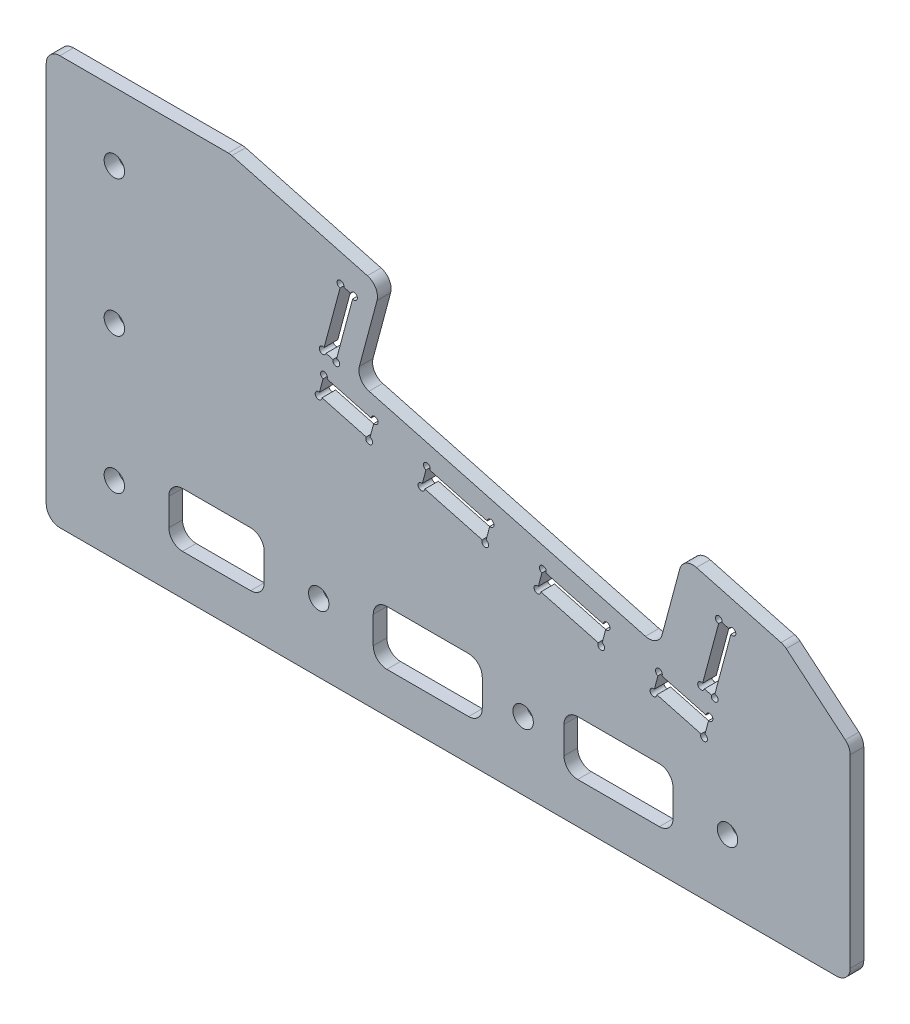
from build123d import *

# Parameters (mm, degrees)
SKETCH_1_W           = 130
SKETCH_1_H           = 60
SKETCH_1_R           = 1.5
EXTRUDE_1_DEPTH      = 2
CUT_EXTRUDE_1_DEPTH  = 3
CUT_EXTRUDE_2_DEPTH  = 3
CUT_EXTRUDE_5_DEPTH  = 10
CUT_EXTRUDE_6_DEPTH  = 3
FILLET_1_R           = 2
CUT_EXTRUDE_7_DEPTH  = 3
CUT_EXTRUDE_8_DEPTH  = 10
CUT_EXTRUDE_9_DEPTH  = 10
EXTRUDE_2_DEPTH      = 2
SKETCH_9_R           = 0.5
CUT_EXTRUDE_10_DEPTH = 10


with BuildPart() as part:
    # 草图1 → 凸台-拉伸1 (new body)
    with BuildSketch(Plane.XY):
        with Locations((65, 30)):
            Rectangle(SKETCH_1_W, SKETCH_1_H)
        with Locations((10, 10)):
            Circle(SKETCH_1_R, mode=Mode.SUBTRACT)
        with Locations((10, 30)):
            Circle(SKETCH_1_R, mode=Mode.SUBTRACT)
        with Locations((10, 50)):
            Circle(SKETCH_1_R, mode=Mode.SUBTRACT)
        with Locations((40, 10)):
            Circle(SKETCH_1_R, mode=Mode.SUBTRACT)
        with Locations((70, 10)):
            Circle(SKETCH_1_R, mode=Mode.SUBTRACT)
        with Locations((100, 10)):
            Circle(SKETCH_1_R, mode=Mode.SUBTRACT)
    extrude(amount=EXTRUDE_1_DEPTH)

    # 草图2 → 切除-拉伸1 (cut, through all)
    with BuildSketch(Plane.XY.offset(2)):
        Polygon((27, 60), (130, 32.40123318), (130, 60), align=None)
    extrude(amount=-CUT_EXTRUDE_1_DEPTH, mode=Mode.SUBTRACT)

    # 草图3 → 切除-拉伸2 (cut, through all)
    with BuildSketch(Plane.XY.offset(2)):
        Polygon((49.071405131, 54.085984819), (93.50399314, 42.180308745), (89.880526509, 28.657347177), (45.447938499, 40.563023251), align=None)
    extrude(amount=-CUT_EXTRUDE_2_DEPTH, mode=Mode.SUBTRACT)

    # 草图4 → 切除-拉伸5 (cut)
    with BuildSketch(Plane.XY.offset(2)):
        Polygon((98.74723483, 36.634281646), (96.159044379, 26.975023383), (98.090896032, 26.457385293), (100.679086483, 36.116643556), align=None)
        Polygon((45.138351471, 50.99873865), (42.55016102, 41.339480387), (40.618309368, 41.857118477), (43.206499819, 51.51637674), align=None)
    extrude(amount=-CUT_EXTRUDE_5_DEPTH, mode=Mode.SUBTRACT)

    # 草图5 → 切除-拉伸6 (cut, through all)
    with BuildSketch(Plane.XY.offset(2)):
        Polygon((130, 20), (130, 32.40123318), (108.287273653, 38.21914067), (118, 30.069195574), (118, 0), (130, 0), align=None)
    extrude(amount=-CUT_EXTRUDE_6_DEPTH, mode=Mode.SUBTRACT)

    # 圆角1
    fillet_1_edges = [part.edges().sort_by_distance(p)[0] for p in [
        (118, 30.069195574, 1),
        (108.287273653, 38.21914067, 1),
        (118, 0, 1),
        (27, 60, 1),
        (45.447938499, 40.563023251, 1),
        (49.071405131, 54.085984819, 1),
        (93.50399314, 42.180308745, 1),
        (89.880526509, 28.657347177, 1),
        (0, 60, 1),
        (0, 0, 1),
    ]]
    fillet(fillet_1_edges, radius=FILLET_1_R)

    # 草图6 → 切除-拉伸7 (cut)
    with BuildSketch(Plane(origin=(0, 0, 0), x_dir=(-1, 0, 0), z_dir=(0, 0, -1))):
        with BuildLine():
            Line((-78, 14), (-90, 14))
            ThreePointArc((-90, 14), (-91.414213562, 13.414213562), (-92, 12))
            Line((-92, 12), (-92, 8))
            ThreePointArc((-92, 8), (-91.414213562, 6.585786438), (-90, 6))
            Line((-90, 6), (-78, 6))
            ThreePointArc((-78, 6), (-76.585786438, 6.585786438), (-76, 8))
            Line((-76, 8), (-76, 12))
            ThreePointArc((-76, 12), (-76.585786438, 13.414213562), (-78, 14))
        make_face()
        with BuildLine():
            Line((-50, 14), (-62, 14))
            ThreePointArc((-62, 14), (-63.414213562, 13.414213562), (-64, 12))
            Line((-64, 12), (-64, 8))
            ThreePointArc((-64, 8), (-63.414213562, 6.585786438), (-62, 6))
            Line((-62, 6), (-50, 6))
            ThreePointArc((-50, 6), (-48.585786438, 6.585786438), (-48, 8))
            Line((-48, 8), (-48, 12))
            ThreePointArc((-48, 12), (-48.585786438, 13.414213562), (-50, 14))
        make_face()
        with BuildLine():
            Line((-20, 14), (-30, 14))
            ThreePointArc((-30, 14), (-31.414213562, 13.414213562), (-32, 12))
            Line((-32, 12), (-32, 8))
            ThreePointArc((-32, 8), (-31.414213562, 6.585786438), (-30, 6))
            Line((-30, 6), (-20, 6))
            ThreePointArc((-20, 6), (-18.585786438, 6.585786438), (-18, 8))
            Line((-18, 8), (-18, 12))
            ThreePointArc((-18, 12), (-18.585786438, 13.414213562), (-20, 14))
        make_face()
    extrude(amount=-CUT_EXTRUDE_7_DEPTH, mode=Mode.SUBTRACT)

    # 草图7 → 切除-拉伸8 (cut)
    with BuildSketch(Plane.XY.offset(2)):
        Polygon((97.314438897, 23.559607814), (89.944424842, 25.534397129), (89.167967707, 22.63661965), (96.537981761, 20.661830336), align=None)
        Polygon((81.440561097, 24.70717201), (82.217018232, 27.604949489), (72.915152525, 30.097376894), (72.138695389, 27.199599415), align=None)
        Polygon((64.411288779, 29.270151776), (65.187745914, 32.167929255), (55.885880207, 34.660356659), (55.109423072, 31.76257918), align=None)
        Polygon((47.382016462, 33.833131541), (48.158473597, 36.73090902), (40.788459542, 38.705698334), (40.012002407, 35.807920855), align=None)
    extrude(amount=-CUT_EXTRUDE_8_DEPTH, mode=Mode.SUBTRACT)

    # 草图8 → 切除-拉伸9 (cut)
    with BuildSketch(Plane.XY.offset(2)):
        Polygon((98.726021627, 36.671023993), (96.122302033, 26.95381018), (98.112109235, 26.420642947), (100.715828829, 36.13785676), align=None)
        Polygon((97.351181243, 23.580821018), (89.923211639, 25.571139475), (89.131225361, 22.615406446), (96.559194965, 20.625087989), align=None)
        Polygon((81.4617743, 24.670429664), (82.253760578, 27.626162693), (72.893939321, 30.13411924), (72.101953043, 27.178386211), align=None)
        Polygon((64.432501982, 29.23340943), (65.22448826, 32.189142458), (55.864667004, 34.697099005), (55.072680726, 31.741365977), align=None)
        Polygon((47.403229665, 33.796389195), (48.195215943, 36.752122223), (40.767246339, 38.74244068), (39.975260061, 35.786707652), align=None)
        Polygon((43.185286615, 51.553119086), (40.581567022, 41.835905273), (42.571374224, 41.302738041), (45.175093818, 51.019951853), align=None)
    extrude(amount=-CUT_EXTRUDE_9_DEPTH, mode=Mode.SUBTRACT)

    # 草图10 → 凸台-拉伸2 (add)
    with BuildSketch(Plane.XY.offset(2)):
        Polygon((40.767246339, 38.74244068), (48.195215943, 36.752122223), (48.169334038, 36.65552964), (40.741364434, 38.645848097), align=None)
        Polygon((39.975260061, 35.786707652), (47.403229665, 33.796389195), (47.42911157, 33.892981777), (40.001141965, 35.883300234), align=None)
        Polygon((55.864667004, 34.697099005), (55.838785099, 34.600506422), (65.196979694, 32.092985738), (65.222861598, 32.189578321), align=None)
        Polygon((64.432501982, 29.23340943), (55.072680726, 31.741365977), (55.09856263, 31.837958559), (64.458383887, 29.330002012), align=None)
        Polygon((72.893939321, 30.13411924), (82.253760578, 27.626162693), (82.227878673, 27.52957011), (72.868057417, 30.037526657), align=None)
        Polygon((81.4617743, 24.670429664), (72.101953043, 27.178386211), (72.127834948, 27.274978794), (81.487656204, 24.767022247), align=None)
        Polygon((89.923211639, 25.571139475), (97.351181243, 23.580821018), (97.325299338, 23.484228435), (89.897329734, 25.474546892), align=None)
        Polygon((96.559194965, 20.625087989), (89.131225361, 22.615406446), (89.157107265, 22.711999029), (96.585076869, 20.721680572), align=None)
        Polygon((98.726021627, 36.671023993), (96.122302033, 26.95381018), (96.218894616, 26.927928276), (98.82261421, 36.645142088), align=None)
        Polygon((100.715828829, 36.13785676), (98.112109235, 26.420642947), (98.015516653, 26.446524852), (100.619236247, 36.163738664), align=None)
        Polygon((43.185286615, 51.553119086), (40.581567022, 41.835905273), (40.658841088, 41.81519975), (43.262560682, 51.532413562), align=None)
        Polygon((45.175093818, 51.019951853), (42.571374224, 41.302738041), (42.494100158, 41.323443564), (45.097819751, 51.040657377), align=None)
    extrude(amount=-EXTRUDE_2_DEPTH)

    # 草图9 → 切除-拉伸10 (cut)
    with BuildSketch(Plane.XY.offset(2)):
        with Locations((43.185286615, 51.553119086)):
            Circle(SKETCH_9_R)
        with Locations((45.175093818, 51.019951853)):
            Circle(SKETCH_9_R)
        with Locations((40.581567022, 41.835905273)):
            Circle(SKETCH_9_R)
        with Locations((42.571374224, 41.302738041)):
            Circle(SKETCH_9_R)
        with Locations((40.767246339, 38.74244068)):
            Circle(SKETCH_9_R)
        with Locations((48.195215943, 36.752122223)):
            Circle(SKETCH_9_R)
        with Locations((39.975260061, 35.786707652)):
            Circle(SKETCH_9_R)
        with Locations((47.403229665, 33.796389195)):
            Circle(SKETCH_9_R)
        with Locations((55.864667004, 34.697099005)):
            Circle(SKETCH_9_R)
        with Locations((55.072680726, 31.741365977)):
            Circle(SKETCH_9_R)
        with Locations((65.22448826, 32.189142458)):
            Circle(SKETCH_9_R)
        with Locations((64.432501982, 29.23340943)):
            Circle(SKETCH_9_R)
        with Locations((72.101953043, 27.178386211)):
            Circle(SKETCH_9_R)
        with Locations((72.893939321, 30.13411924)):
            Circle(SKETCH_9_R)
        with Locations((82.253760578, 27.626162693)):
            Circle(SKETCH_9_R)
        with Locations((81.4617743, 24.670429664)):
            Circle(SKETCH_9_R)
        with Locations((89.131225361, 22.615406446)):
            Circle(SKETCH_9_R)
        with Locations((89.923211639, 25.571139475)):
            Circle(SKETCH_9_R)
        with Locations((97.351181243, 23.580821018)):
            Circle(SKETCH_9_R)
        with Locations((96.559194965, 20.625087989)):
            Circle(SKETCH_9_R)
        with Locations((96.122302033, 26.95381018)):
            Circle(SKETCH_9_R)
        with Locations((98.112109235, 26.420642947)):
            Circle(SKETCH_9_R)
        with Locations((98.726021627, 36.671023993)):
            Circle(SKETCH_9_R)
        with Locations((100.715828829, 36.13785676)):
            Circle(SKETCH_9_R)
    extrude(amount=-CUT_EXTRUDE_10_DEPTH, mode=Mode.SUBTRACT)


solid = part.part
